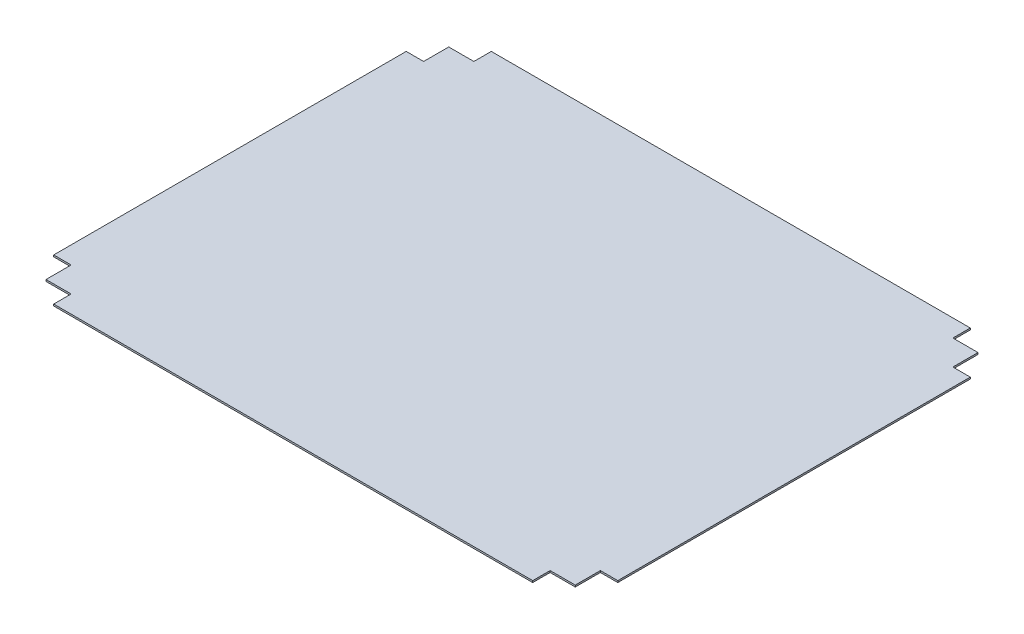
from build123d import *

# Parameters (mm, degrees)
BOSS_EXTRUDE1_DEPTH = 2


with BuildPart() as part:
    # Sketch1 → Boss-Extrude1 (new body)
    with BuildSketch(Plane(origin=(0, 0, 0), x_dir=(1, 0, 0), z_dir=(0, 1, 0))):
        Polygon((-276.39978149, -252.50021851), (-276.39978149, -232.401081902), (-305.39978149, -232.401081902), (-305.39978149, -203.401081902), (-325.50021851, -203.401081902), (-325.50021851, 203.401101302), (-305.39978149, 203.401101302), (-305.39978149, 232.401101302), (-276.39978149, 232.401101302), (-276.39978149, 252.50021851), (276.401533304, 252.50021851), (276.401533304, 232.401101302), (305.401533304, 232.401101302), (305.401533304, 203.401101302), (325.50021851, 203.401101302), (325.50021851, -203.401081902), (305.401533304, -203.401081902), (305.401533304, -232.401081902), (276.401533304, -232.401081902), (276.401533304, -252.50021851), align=None)
    extrude(amount=BOSS_EXTRUDE1_DEPTH)


solid = part.part
